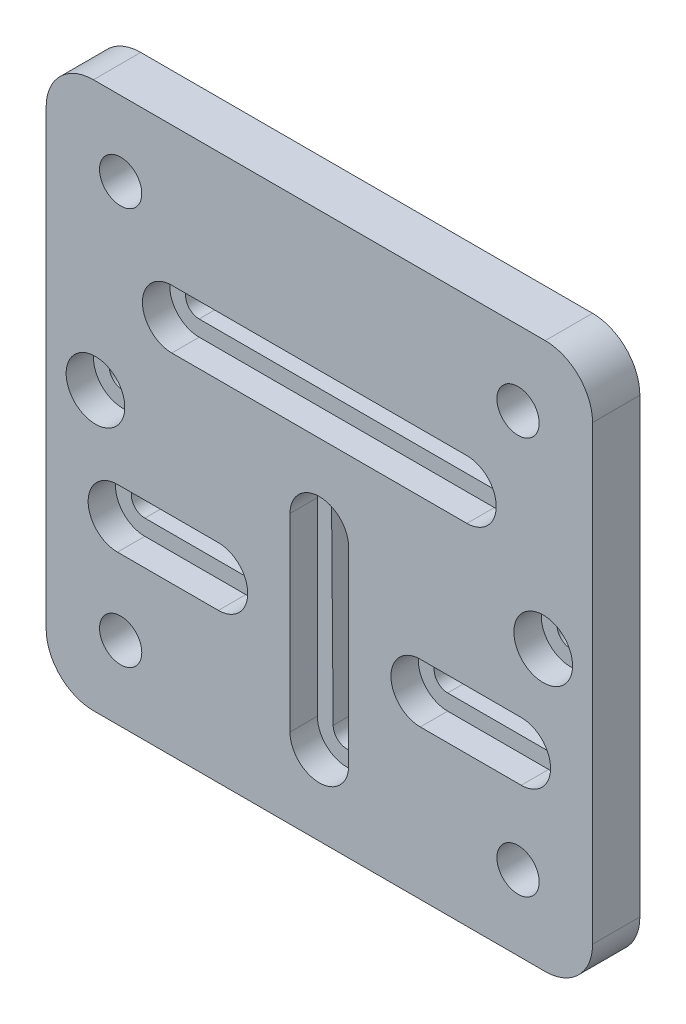
from build123d import *

# Parameters (mm, degrees)
SKETCH1_W           = 109.99978
SKETCH1_H           = 109.99978
BOSS_EXTRUDE1_DEPTH = 9.525
SKETCH2_R           = 5.9055
CUT_EXTRUDE1_DEPTH  = 5.5118
SKETCH3_R           = 2.7305
CUT_EXTRUDE3_DEPTH  = 10.525
SKETCH4_R           = 4.2545
CUT_EXTRUDE4_DEPTH  = 10.525
FILLET1_R           = 9.525


with BuildPart() as part:
    # Sketch1 → Boss-Extrude1 (new body)
    with BuildSketch(Plane.XY):
        Rectangle(SKETCH1_W, SKETCH1_H)
    extrude(amount=-BOSS_EXTRUDE1_DEPTH)

    # Sketch2 → Cut-Extrude1 (cut)
    with BuildSketch(Plane.XY):
        with Locations((45.06849, 1.06299)):
            Circle(SKETCH2_R)
        with Locations((-45.06849, 1.06299)):
            Circle(SKETCH2_R)
        with BuildLine():
            Line((-29.7053, 27.05989), (29.7053, 27.05989))
            ThreePointArc((29.7053, 27.05989), (35.6108, 21.15439), (29.7053, 15.24889))
            Line((29.7053, 15.24889), (-29.7053, 15.24889))
            ThreePointArc((-29.7053, 15.24889), (-35.6108, 21.15439), (-29.7053, 27.05989))
        make_face()
        with BuildLine():
            Line((-5.9055, -0.8255), (-5.9055, -38.9255))
            ThreePointArc((-5.9055, -38.9255), (0, -44.831), (5.9055, -38.9255))
            Line((5.9055, -38.9255), (5.9055, -0.8255))
            ThreePointArc((5.9055, -0.8255), (0, 5.08), (-5.9055, -0.8255))
        make_face()
        with BuildLine():
            Line((20.32, -13.12291), (40.64, -13.12291))
            ThreePointArc((40.64, -13.12291), (46.5455, -19.02841), (40.64, -24.93391))
            Line((40.64, -24.93391), (20.32, -24.93391))
            ThreePointArc((20.32, -24.93391), (14.4145, -19.02841), (20.32, -13.12291))
        make_face()
        with BuildLine():
            Line((-20.32, -13.12291), (-40.64, -13.12291))
            ThreePointArc((-40.64, -13.12291), (-46.5455, -19.02841), (-40.64, -24.93391))
            Line((-40.64, -24.93391), (-20.32, -24.93391))
            ThreePointArc((-20.32, -24.93391), (-14.4145, -19.02841), (-20.32, -13.12291))
        make_face()
    extrude(amount=-CUT_EXTRUDE1_DEPTH, mode=Mode.SUBTRACT)

    # Sketch3 → Cut-Extrude3 (cut, through all)
    with BuildSketch(Plane.XY):
        with BuildLine():
            ThreePointArc((29.7053, 23.88489), (32.4358, 21.15439), (29.7053, 18.42389))
            Line((29.7053, 18.42389), (-29.7053, 18.42389))
            ThreePointArc((-29.7053, 18.42389), (-32.4358, 21.15439), (-29.7053, 23.88489))
            Line((-29.7053, 23.88489), (29.7053, 23.88489))
        make_face()
        with BuildLine():
            Line((3.048, -0.8255), (2.7305, -38.9255))
            ThreePointArc((2.7305, -38.9255), (0, -41.656), (-2.7305, -38.9255))
            Line((-2.7305, -38.9255), (-3.048, -0.8255))
            ThreePointArc((-3.048, -0.8255), (0, 2.2225), (3.048, -0.8255))
        make_face()
        with BuildLine():
            Line((-20.32, -16.29791), (-40.64, -16.29791))
            ThreePointArc((-40.64, -16.29791), (-43.3705, -19.02841), (-40.64, -21.75891))
            Line((-40.64, -21.75891), (-20.32, -21.75891))
            ThreePointArc((-20.32, -21.75891), (-17.5895, -19.02841), (-20.32, -16.29791))
        make_face()
        with BuildLine():
            ThreePointArc((40.64, -16.29791), (43.3705, -19.02841), (40.64, -21.75891))
            Line((40.64, -21.75891), (20.32, -21.75891))
            ThreePointArc((20.32, -21.75891), (17.5895, -19.02841), (20.32, -16.29791))
            Line((20.32, -16.29791), (40.64, -16.29791))
        make_face()
        with Locations((-45.06849, 1.06299)):
            Circle(SKETCH3_R)
        with Locations((45.06849, 1.06299)):
            Circle(SKETCH3_R)
    extrude(amount=-CUT_EXTRUDE3_DEPTH, mode=Mode.SUBTRACT)

    # Sketch4 → Cut-Extrude4 (cut, through all)
    with BuildSketch(Plane.XY):
        with Locations((-39.99865, -39.99865)):
            Circle(SKETCH4_R)
        with Locations((-39.99865, 39.99865)):
            Circle(SKETCH4_R)
        with Locations((39.99865, -39.99865)):
            Circle(SKETCH4_R)
        with Locations((39.99865, 39.99865)):
            Circle(SKETCH4_R)
    extrude(amount=-CUT_EXTRUDE4_DEPTH, mode=Mode.SUBTRACT)

    # Fillet1
    fillet1_edges = [part.edges().sort_by_distance(p)[0] for p in [
        (-54.99989, 54.99989, -4.7625),
        (-54.99989, -54.99989, -4.7625),
        (54.99989, -54.99989, -4.7625),
        (54.99989, 54.99989, -4.7625),
    ]]
    fillet(fillet1_edges, radius=FILLET1_R)


solid = part.part
